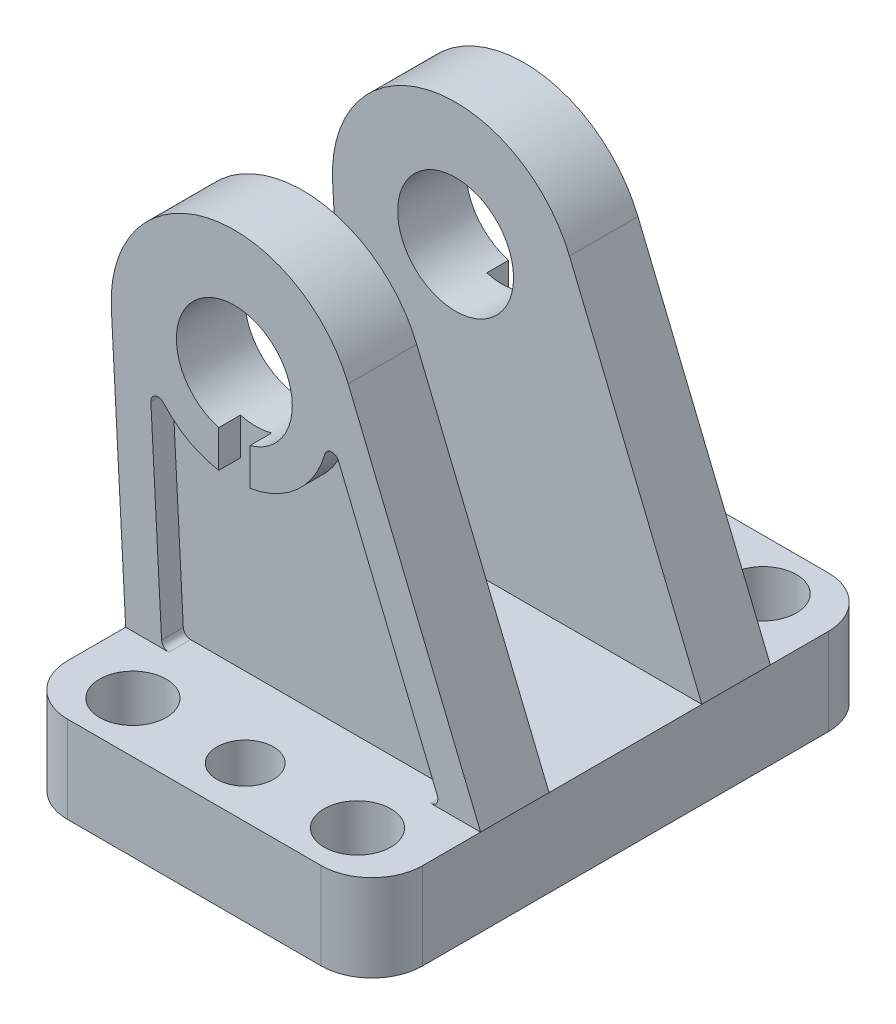
from build123d import *

# Parameters (mm, degrees)
SKETCH1_R               = 4.6
SKETCH1_R_2             = 3.9
BOSS_EXTRUDE1_DEPTH     = 12
CUT_EXTRUDE1_DEPTH      = 6
SKETCH3_R               = 8
BOSS_EXTRUDE2_DEPTH     = 9.45
CUT_EXTRUDE2_DEPTH      = 3
SKETCH5_R               = 8
BOSS_EXTRUDE3_DEPTH     = 9.45
CUT_EXTRUDE3_DEPTH      = 3
CUT_EXTRUDE4_DEPTH      = 3
CUT_EXTRUDE4_DEPTH_BACK = 3
CUT_EXTRUDE5_DEPTH      = 3
CUT_EXTRUDE5_DEPTH_BACK = 3


with BuildPart() as part:
    # Sketch1 → Boss-Extrude1 (new body)
    with BuildSketch(Plane(origin=(0, 0, 0), x_dir=(1, 0, 0), z_dir=(0, 1, 0))):
        with BuildLine():
            Line((-17.5, -35), (17.5, -35))
            ThreePointArc((17.5, -35), (22.449747468, -32.949747468), (24.5, -28))
            Line((24.5, -28), (24.5, 28))
            ThreePointArc((24.5, 28), (22.449747468, 32.949747468), (17.5, 35))
            Line((17.5, 35), (-17.5, 35))
            ThreePointArc((-17.5, 35), (-22.449747468, 32.949747468), (-24.5, 28))
            Line((-24.5, 28), (-24.5, -28))
            ThreePointArc((-24.5, -28), (-22.449747468, -32.949747468), (-17.5, -35))
        make_face()
        with Locations((15.5, 28)):
            Circle(SKETCH1_R, mode=Mode.SUBTRACT)
        with Locations((15.5, -28)):
            Circle(SKETCH1_R, mode=Mode.SUBTRACT)
        with Locations((0, 28)):
            Circle(SKETCH1_R_2, mode=Mode.SUBTRACT)
        with Locations((0, -28)):
            Circle(SKETCH1_R_2, mode=Mode.SUBTRACT)
        with Locations((-15.5, 28)):
            Circle(SKETCH1_R, mode=Mode.SUBTRACT)
        with Locations((-15.5, -28)):
            Circle(SKETCH1_R, mode=Mode.SUBTRACT)
    extrude(amount=BOSS_EXTRUDE1_DEPTH)

    # Sketch2 → Cut-Extrude1 (cut)
    with BuildSketch(Plane(origin=(0, 0, 0), x_dir=(1, 0, 0), z_dir=(0, 1, 0))):
        with BuildLine():
            Line((-8.930372918, -22), (8.930372918, -22))
            ThreePointArc((8.930372918, -22), (9.298362954, -21.929829734), (9.614709072, -21.729166667))
            ThreePointArc((9.614709072, -21.729166667), (13.6405636, -19.603423539), (18.1875, -19.830707267))
            ThreePointArc((18.1875, -19.830707267), (19.08630197, -19.690882095), (19.5, -18.880789508))
            Line((19.5, -18.880789508), (19.5, 18.880789508))
            ThreePointArc((19.5, 18.880789508), (19.08630197, 19.690882095), (18.1875, 19.830707267))
            ThreePointArc((18.1875, 19.830707267), (13.6405636, 19.603423539), (9.614709072, 21.729166667))
            ThreePointArc((9.614709072, 21.729166667), (9.298362954, 21.929829734), (8.930372918, 22))
            Line((8.930372918, 22), (-8.930372918, 22))
            ThreePointArc((-8.930372918, 22), (-9.298362954, 21.929829734), (-9.614709072, 21.729166667))
            ThreePointArc((-9.614709072, 21.729166667), (-13.6405636, 19.603423539), (-18.1875, 19.830707267))
            ThreePointArc((-18.1875, 19.830707267), (-19.08630197, 19.690882095), (-19.5, 18.880789508))
            Line((-19.5, 18.880789508), (-19.5, -18.880789508))
            ThreePointArc((-19.5, -18.880789508), (-19.086301938, -19.690882118), (-18.187499925, -19.830707243))
            ThreePointArc((-18.187499925, -19.830707243), (-13.640563561, -19.603423547), (-9.614709072, -21.729166667))
            ThreePointArc((-9.614709072, -21.729166667), (-9.298362954, -21.929829734), (-8.930372918, -22))
        make_face()
    extrude(amount=CUT_EXTRUDE1_DEPTH, mode=Mode.SUBTRACT)

    # Sketch3 → Boss-Extrude2 (add)
    with BuildSketch(Plane.XY.offset(20)):
        with BuildLine():
            Line((-26.475934633, 49.095763671), (-24.5, 12))
            Line((-24.5, 12), (24.5, 12))
            Line((24.5, 12), (6.223487863, 56.463120719))
            ThreePointArc((6.223487863, 56.463120719), (-13.236528228, 66.584280413), (-26.475934633, 49.095763671))
        make_face()
        with Locations((-9.5, 50)):
            Circle(SKETCH3_R, mode=Mode.SUBTRACT)
    extrude(amount=-BOSS_EXTRUDE2_DEPTH)

    # Sketch4 → Cut-Extrude2 (cut)
    with BuildSketch(Plane.XY.offset(20)):
        with BuildLine():
            Line((-21.022370546, 40.713721035), (-19.543344466, 12.946809628))
            ThreePointArc((-19.543344466, 12.946809628), (-19.232804271, 12.274331215), (-18.544760076, 12))
            Line((-18.544760076, 12), (17.60184091, 12))
            ThreePointArc((17.60184091, 12), (18.432558544, 12.443305996), (18.526751961, 13.380183572))
            Line((18.526751961, 13.380183572), (4.891418921, 46.552238199))
            ThreePointArc((4.891418921, 46.552238199), (3.910016369, 47.170457707), (3.004614451, 46.445479297))
            ThreePointArc((3.004614451, 46.445479297), (-6.642654885, 37.317903214), (-19.272087144, 41.426417736))
            ThreePointArc((-19.272087144, 41.426417736), (-20.400909801, 41.693074328), (-21.022370546, 40.713721035))
        make_face()
    extrude(amount=-CUT_EXTRUDE2_DEPTH, mode=Mode.SUBTRACT)

    # Sketch5 → Boss-Extrude3 (add)
    with BuildSketch(Plane.XY.offset(-20)):
        with BuildLine():
            Line((-26.475934633, 49.095763671), (-24.5, 12))
            Line((-24.5, 12), (24.5, 12))
            Line((24.5, 12), (6.223487863, 56.463120719))
            ThreePointArc((6.223487863, 56.463120719), (-13.236528228, 66.584280413), (-26.475934633, 49.095763671))
        make_face()
        with Locations((-9.5, 50)):
            Circle(SKETCH5_R, mode=Mode.SUBTRACT)
    extrude(amount=BOSS_EXTRUDE3_DEPTH)

    # Sketch6 → Cut-Extrude3 (cut)
    with BuildSketch(Plane.XY.offset(-20)):
        with BuildLine():
            Line((-21.022370546, 40.713721035), (-19.543344466, 12.946809628))
            ThreePointArc((-19.543344466, 12.946809628), (-19.232804271, 12.274331215), (-18.544760076, 12))
            Line((-18.544760076, 12), (17.60184091, 12))
            ThreePointArc((17.60184091, 12), (18.432558544, 12.443305996), (18.526751961, 13.380183572))
            Line((18.526751961, 13.380183572), (4.891418921, 46.552238199))
            ThreePointArc((4.891418921, 46.552238199), (3.910016369, 47.170457707), (3.004614451, 46.445479297))
            ThreePointArc((3.004614451, 46.445479297), (-6.642654885, 37.317903214), (-19.272087144, 41.426417736))
            ThreePointArc((-19.272087144, 41.426417736), (-20.400909801, 41.693074328), (-21.022370546, 40.713721035))
        make_face()
    extrude(amount=CUT_EXTRUDE3_DEPTH, mode=Mode.SUBTRACT)

    # Sketch7 → Cut-Extrude4 (cut, two sides)
    with BuildSketch(Plane.XY.offset(20)) as cut_extrude4_sk:
        with BuildLine():
            Line((-7.35, 35.15), (-7.35, 50))
            Line((-7.35, 50), (-11.65, 50))
            Line((-11.65, 50), (-11.65, 35.15))
            ThreePointArc((-11.65, 35.15), (-9.5, 33), (-7.35, 35.15))
        make_face()
    extrude(amount=CUT_EXTRUDE4_DEPTH, mode=Mode.SUBTRACT)
    extrude(cut_extrude4_sk.sketch, amount=-CUT_EXTRUDE4_DEPTH_BACK, mode=Mode.SUBTRACT)

    # Sketch8 → Cut-Extrude5 (cut, two sides)
    with BuildSketch(Plane.XY.offset(-20)) as cut_extrude5_sk:
        with BuildLine():
            Line((-7.35, 35.15), (-7.35, 50))
            Line((-7.35, 50), (-11.65, 50))
            Line((-11.65, 50), (-11.65, 35.15))
            ThreePointArc((-11.65, 35.15), (-9.5, 33), (-7.35, 35.15))
        make_face()
    extrude(amount=CUT_EXTRUDE5_DEPTH, mode=Mode.SUBTRACT)
    extrude(cut_extrude5_sk.sketch, amount=-CUT_EXTRUDE5_DEPTH_BACK, mode=Mode.SUBTRACT)


solid = part.part
